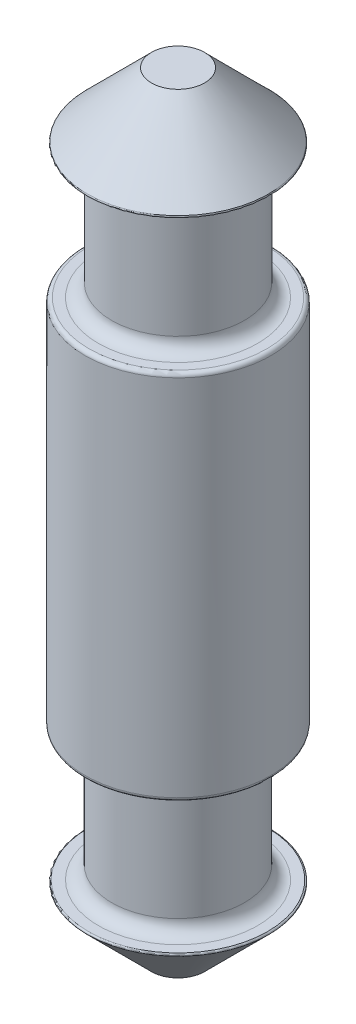
from build123d import *

# Parameters (mm, degrees)
SKETCH1_R           = 7
BOSS_EXTRUDE1_DEPTH = 14
SKETCH2_R           = 5
BOSS_EXTRUDE2_DEPTH = 10
SKETCH4_R           = 7
BOSS_EXTRUDE4_DEPTH = 5
BOSS_EXTRUDE4_TAPER = 45
FILLET1_R           = 0.1
FILLET3_R           = 0.3
FILLET4_R           = 1
FILLET5_R           = 1


with BuildPart() as part:
    # Sketch1 → Boss-Extrude1 (new body)
    with BuildSketch(Plane(origin=(0, 0, 0), x_dir=(1, 0, 0), z_dir=(0, 1, 0))):
        Circle(SKETCH1_R)
    extrude(amount=BOSS_EXTRUDE1_DEPTH)

    # Sketch2 → Boss-Extrude2 (add)
    with BuildSketch(Plane(origin=(0, 14, 0), x_dir=(1, 0, 0), z_dir=(0, 1, 0))):
        Circle(SKETCH2_R)
    extrude(amount=BOSS_EXTRUDE2_DEPTH)

    # Sketch4 → Boss-Extrude4 (add)
    with BuildSketch(Plane(origin=(0, 24, 0), x_dir=(1, 0, 0), z_dir=(0, 1, 0))):
        Circle(SKETCH4_R)
    extrude(amount=BOSS_EXTRUDE4_DEPTH, taper=BOSS_EXTRUDE4_TAPER)

    # Fillet1
    fillet1_edges = [part.edges().sort_by_distance(p)[0] for p in [
        (-7, 24, 0),
    ]]
    fillet(fillet1_edges, radius=FILLET1_R)

    # Mirror1: part across plane


with BuildPart() as part_1:
    add(part.part)
    add(part.part.mirror(Plane.ZX))

    # Fillet3
    fillet3_edges = [part_1.edges().sort_by_distance(p)[0] for p in [
        (-7, -14, 0),
        (-7, 14, 0),
    ]]
    fillet(fillet3_edges, radius=FILLET3_R)

    # Fillet4
    fillet4_edges = [part_1.edges().sort_by_distance(p)[0] for p in [
        (-5, -24, 0),
        (-5, 24, 0),
    ]]
    fillet(fillet4_edges, radius=FILLET4_R)

    # Fillet5
    fillet5_edges = [part_1.edges().sort_by_distance(p)[0] for p in [
        (-5, -14, 0),
        (-5, 14, 0),
    ]]
    fillet(fillet5_edges, radius=FILLET5_R)


solid = part_1.part
